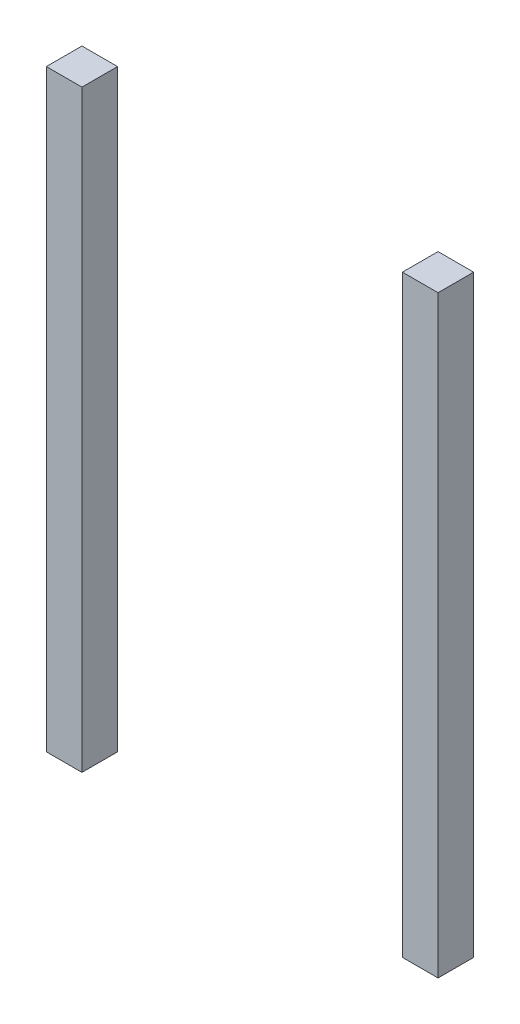
from build123d import *

# Parameters (mm, degrees)
SKIZZE1_W                         = 30
SKIZZE1_H                         = 500
AUFSATZ_LINEAR_AUSTRAGEN1_DEPTH   = 30
AUFSATZ_LINEAR_AUSTRAGEN1_2_DEPTH = 30


with BuildPart() as part:
    # Skizze1 → Aufsatz-Linear austragen1 (new body)
    with BuildSketch(Plane.XY):
        with Locations((-150, 0)):
            Rectangle(SKIZZE1_W, SKIZZE1_H)
    extrude(amount=AUFSATZ_LINEAR_AUSTRAGEN1_DEPTH)


with BuildPart() as body_2:
    # Skizze1 → Aufsatz-Linear austragen1 2 (new body)
    with BuildSketch(Plane.XY):
        with Locations((150, 0)):
            Rectangle(SKIZZE1_W, SKIZZE1_H)
    extrude(amount=AUFSATZ_LINEAR_AUSTRAGEN1_2_DEPTH)


solid = Compound([part.part, body_2.part])
